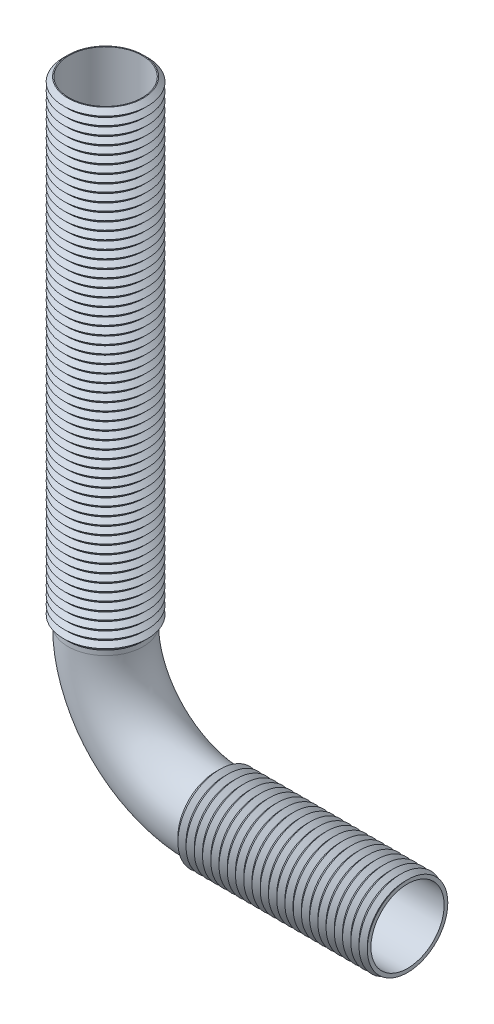
from build123d import *

# Parameters (mm, degrees)
SWEEP_THIN1_PROFILE_R   = 82
SWEEP_THIN1_PROFILE_R_2 = 80


with BuildPart() as part:
    # Sweep-Thin1: sweep along a path in Sketch1
    with BuildLine(Plane.XY) as sweep_thin1_path:
        Line((-238.904761905, 770.261904762), (-238.904761905, -267.738095238))
        ThreePointArc((-238.904761905, -267.738095238), (-168.61038939, -437.443722723), (1.095238095, -507.738095238))
        Line((1.095238095, -507.738095238), (421.095238095, -507.738095238))
    # Sweep-Thin1 profile (on start of the path) → Sweep-Thin1 (sweep)
    with BuildSketch(Plane(origin=(-238.904761905, 770.261904762, 0), x_dir=(0, 0, -1), z_dir=(0, -1, 0))):
        Circle(SWEEP_THIN1_PROFILE_R)
        Circle(SWEEP_THIN1_PROFILE_R_2, mode=Mode.SUBTRACT)
    sweep(path=sweep_thin1_path.line)

    # Sketch12 → Revolve2 (revolve)
    with BuildSketch(Plane.XY, mode=Mode.PRIVATE) as revolve2_sk:
        Polygon((-156.904761905, 770.261904762), (-147.005266968, 760.362409825), (-156.005266968, 751.362409825), (-147.005266968, 742.362409825), (-156.005266968, 733.362409825), (-147.005266968, 724.362409825), (-156.005266968, 715.362409825), (-147.005266968, 706.362409825), (-156.005266968, 697.362409825), (-147.005266968, 688.362409825), (-156.005266968, 679.362409825), (-147.005266968, 670.362409825), (-156.005266968, 661.362409825), (-147.005266968, 652.362409825), (-156.005266968, 643.362409825), (-147.005266968, 634.362409825), (-156.005266968, 625.362409825), (-147.005266968, 616.362409825), (-156.005266968, 607.362409825), (-147.005266968, 598.362409825), (-156.005266968, 589.362409825), (-147.005266968, 580.362409825), (-156.005266968, 571.362409825), (-147.005266968, 562.362409825), (-156.005266968, 553.362409825), (-147.005266968, 544.362409825), (-156.005266968, 535.362409825), (-147.005266968, 526.362409825), (-156.005266968, 517.362409825), (-147.005266968, 508.362409825), (-156.005266968, 499.362409825), (-147.005266968, 490.362409825), (-156.005266968, 481.362409825), (-147.005266968, 472.362409825), (-156.005266968, 463.362409825), (-147.005266968, 454.362409825), (-156.005266968, 445.362409825), (-147.005266968, 436.362409825), (-156.005266968, 427.362409825), (-147.005266968, 418.362409825), (-156.005266968, 409.362409825), (-147.005266968, 400.362409825), (-156.005266968, 391.362409825), (-147.005266968, 382.362409825), (-156.005266968, 373.362409825), (-147.005266968, 364.362409825), (-156.005266968, 355.362409825), (-147.005266968, 346.362409825), (-156.005266968, 337.362409825), (-147.005266968, 328.362409825), (-156.005266968, 319.362409825), (-147.005266968, 310.362409825), (-156.005266968, 301.362409825), (-147.005266968, 292.362409825), (-156.005266968, 283.362409825), (-147.005266968, 274.362409825), (-156.005266968, 265.362409825), (-147.005266968, 256.362409825), (-156.005266968, 247.362409825), (-147.005266968, 238.362409825), (-156.005266968, 229.362409825), (-147.005266968, 220.362409825), (-156.005266968, 211.362409825), (-147.005266968, 202.362409825), (-156.005266968, 193.362409825), (-147.005266968, 184.362409825), (-156.005266968, 175.362409825), (-147.005266968, 166.362409825), (-156.005266968, 157.362409825), (-147.005266968, 148.362409825), (-156.005266968, 139.362409825), (-147.005266968, 130.362409825), (-156.005266968, 121.362409825), (-147.005266968, 112.362409825), (-156.005266968, 103.362409825), (-147.005266968, 94.362409825), (-156.005266968, 85.362409825), (-147.005266968, 76.362409825), (-156.005266968, 67.362409825), (-147.005266968, 58.362409825), (-156.005266968, 49.362409825), (-147.005266968, 40.362409825), (-156.005266968, 31.362409825), (-147.005266968, 22.362409825), (-156.005266968, 13.362409825), (-147.005266968, 4.362409825), (-156.005266968, -4.637590175), (-147.005266968, -13.637590175), (-156.005266968, -22.637590175), (-147.005266968, -31.637590175), (-156.005266968, -40.637590175), (-147.005266968, -49.637590175), (-156.005266968, -58.637590175), (-147.005266968, -67.637590175), (-156.005266968, -76.637590175), (-147.005266968, -85.637590175), (-156.005266968, -94.637590175), (-147.005266968, -103.637590175), (-156.005266968, -112.637590175), (-147.005266968, -121.637590175), (-156.005266968, -130.637590175), (-147.005266968, -139.637590175), (-156.005266968, -148.637590175), (-147.005266968, -157.637590175), (-156.005266968, -166.637590175), (-147.005266968, -175.637590175), (-156.005266968, -184.637590175), (-147.005266968, -193.637590175), (-156.005266968, -202.637590175), (-147.005266968, -211.637590175), (-156.005266968, -220.637590175), (-147.005266968, -229.637590175), (-156.005266968, -238.637590175), (-147.005266968, -247.637590175), (-156.904761905, -257.537085111), align=None)
    revolve(revolve2_sk.sketch.rotate(Axis((-238.904761905, 770.261904762, 0), (0, -1, 0)), 180), axis=Axis((-238.904761905, 770.261904762, 0), (0, -1, 0)))

    # Sketch13 → Revolve3 (revolve)
    with BuildSketch(Plane.XY, mode=Mode.PRIVATE) as revolve3_sk:
        Polygon((1.095238095, -425.738095238), (10.994733032, -415.838600301), (19.994733032, -424.838600301), (28.994733032, -415.838600301), (37.994733032, -424.838600301), (46.994733032, -415.838600301), (55.994733032, -424.838600301), (64.994733032, -415.838600301), (73.994733032, -424.838600301), (82.994733032, -415.838600301), (91.994733032, -424.838600301), (100.994733032, -415.838600301), (109.994733032, -424.838600301), (118.994733032, -415.838600301), (127.994733032, -424.838600301), (136.994733032, -415.838600301), (145.994733032, -424.838600301), (154.994733032, -415.838600301), (163.994733032, -424.838600301), (172.994733032, -415.838600301), (181.994733032, -424.838600301), (190.994733032, -415.838600301), (199.994733032, -424.838600301), (208.994733032, -415.838600301), (217.994733032, -424.838600301), (226.994733032, -415.838600301), (235.994733032, -424.838600301), (244.994733032, -415.838600301), (253.994733032, -424.838600301), (262.994733032, -415.838600301), (271.994733032, -424.838600301), (280.994733032, -415.838600301), (289.994733032, -424.838600301), (298.994733032, -415.838600301), (307.994733032, -424.838600301), (316.994733032, -415.838600301), (325.994733032, -424.838600301), (334.994733032, -415.838600301), (343.994733032, -424.838600301), (352.994733032, -415.838600301), (361.994733032, -424.838600301), (370.994733032, -415.838600301), (379.994733032, -424.838600301), (388.994733032, -415.838600301), (397.994733032, -424.838600301), (406.994733032, -415.838600301), (415.994733032, -424.838600301), (421.095238095, -419.738095238), (421.095238095, -425.738095238), align=None)
    revolve(revolve3_sk.sketch.rotate(Axis((421.095238095, -507.738095238, 0), (-1, 0, 0)), 90), axis=Axis((421.095238095, -507.738095238, 0), (-1, 0, 0)))


solid = part.part
